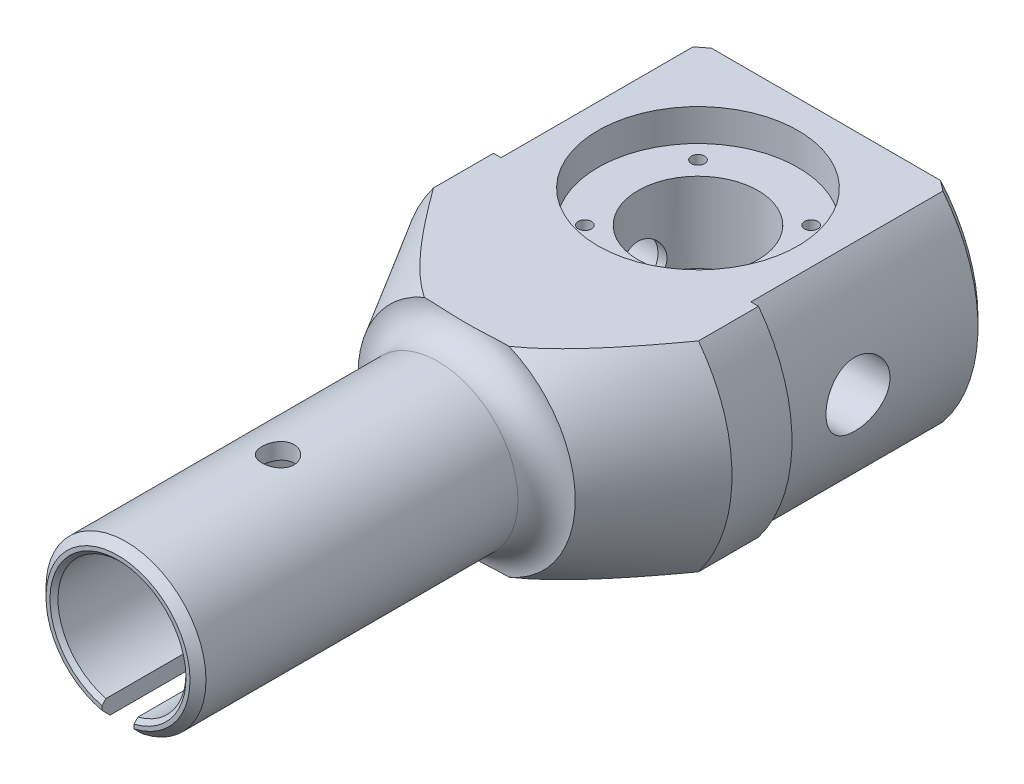
from build123d import *

# Parameters (mm, degrees)
SCHNITT_LINEAR_AUSTRAGEN1_REACH      = 179
SKIZZE3_R                            = 6
SCHNITT_LINEAR_AUSTRAGEN2_DEPTH      = 42.5
SCHNITT_LINEAR_AUSTRAGEN2_DEPTH_BACK = 42.5
SKIZZE4_R                            = 25
SCHNITT_LINEAR_AUSTRAGEN3_DEPTH      = 8
SKIZZE5_R                            = 15
SCHNITT_LINEAR_AUSTRAGEN4_DEPTH      = 20
KREISMUSTER1_COUNT                   = 4
SKIZZE9_R                            = 10
SCHNITT_LINEAR_AUSTRAGEN5_DEPTH      = 7.5
SCHNITT_LINEAR_AUSTRAGEN6_REACH      = 16.5
SKIZZE10_R                           = 7.5
SCHNITT_LINEAR_AUSTRAGEN7_REACH      = 27
SCHNITT_LINEAR_AUSTRAGEN8_REACH      = 27
SCHNITT_LINEAR_AUSTRAGEN8_END_RADIUS = 20
SKIZZE13_R                           = 4
SKIZZE14_R                           = 8
SCHNITT_LINEAR_AUSTRAGEN9_DEPTH      = 24
SKIZZE15_R                           = 8
SCHNITT_LINEAR_AUSTRAGEN10_DEPTH     = 24


with BuildPart() as part:
    # Skizze1 → Rotation1 (revolve)
    with BuildSketch(Plane(origin=(0, 0, 0), x_dir=(0, 0, -1), z_dir=(1, 0, 0)), mode=Mode.PRIVATE) as rotation1_sk:
        with BuildLine():
            Line((0, 0), (0, -38))
            Line((0, -38), (-2, -40))
            Line((-2, -40), (-50, -40))
            Line((-50, -40), (-50, -41.5))
            Line((-50, -41.5), (-65, -41.5))
            Line((-65, -41.5), (-89.84326674, -27.15673326))
            ThreePointArc((-89.84326674, -27.15673326), (-91.939425381, -22.096158641), (-97, -20))
            Line((-97, -20), (-175, -20))
            Line((-175, -20), (-177, -18))
            Line((-177, -18), (-177, -17))
            Line((-177, -17), (-176, -16))
            Line((-176, -16), (-86, -16))
            Line((-86, -16), (-76.386230096, 0))
            Line((-76.386230096, 0), (0, 0))
        make_face()
    revolve(rotation1_sk.sketch.rotate(Axis((0, 0, 212.688910887), (0, 0, -1)), 270), axis=Axis((0, 0, 212.688910887), (0, 0, -1)))  # turned: the seam where the file's is

    # Skizze2 → Schnitt-Linear austragen1 (cut, up to next)
    with BuildSketch(Plane(origin=(0, 0, 0), x_dir=(-1, 0, 0), z_dir=(0, 0, -1)), mode=Mode.PRIVATE) as schnitt_linear_austragen1_sk1:
        with BuildLine():
            Line((28.618176043, -25), (-28.618176043, -25))
            ThreePointArc((-28.618176043, -25), (0, -38), (28.618176043, -25))
        make_face()
    schnitt_linear_austragen1_tool1 = extrude(schnitt_linear_austragen1_sk1.sketch, amount=-SCHNITT_LINEAR_AUSTRAGEN1_REACH, mode=Mode.PRIVATE) & part.part
    add(schnitt_linear_austragen1_tool1.solids().sort_by_distance((0, -30.28468, 0))[0], mode=Mode.SUBTRACT)
    # Skizze2 → Schnitt-Linear austragen1 (cut, up to next)
    with BuildSketch(Plane(origin=(0, 0, 0), x_dir=(-1, 0, 0), z_dir=(0, 0, -1)), mode=Mode.PRIVATE) as schnitt_linear_austragen1_sk2:
        with BuildLine():
            ThreePointArc((28.618176043, 25), (0, 38), (-28.618176043, 25))
            Line((-28.618176043, 25), (28.618176043, 25))
        make_face()
    schnitt_linear_austragen1_tool2 = extrude(schnitt_linear_austragen1_sk2.sketch, amount=-SCHNITT_LINEAR_AUSTRAGEN1_REACH, mode=Mode.PRIVATE) & part.part
    add(schnitt_linear_austragen1_tool2.solids().sort_by_distance((0, 30.28468, 0))[0], mode=Mode.SUBTRACT)
    # Skizze2 → Schnitt-Linear austragen1 (cut, up to next)
    with BuildSketch(Plane(origin=(0, 0, 0), x_dir=(-1, 0, 0), z_dir=(0, 0, -1)), mode=Mode.PRIVATE) as schnitt_linear_austragen1_sk3:
        with BuildLine():
            ThreePointArc((33.749074061, 25), (0, 42), (-33.749074061, 25))
            Line((-33.749074061, 25), (-28.618176043, 25))
            ThreePointArc((-28.618176043, 25), (0, 38), (28.618176043, 25))
            Line((28.618176043, 25), (33.749074061, 25))
        make_face()
    schnitt_linear_austragen1_tool3 = extrude(schnitt_linear_austragen1_sk3.sketch, amount=-SCHNITT_LINEAR_AUSTRAGEN1_REACH, mode=Mode.PRIVATE) & part.part
    add(schnitt_linear_austragen1_tool3.solids().sort_by_distance((0, 38.69606, 0))[0], mode=Mode.SUBTRACT)
    # Skizze2 → Schnitt-Linear austragen1 (cut, up to next)
    with BuildSketch(Plane(origin=(0, 0, 0), x_dir=(-1, 0, 0), z_dir=(0, 0, -1)), mode=Mode.PRIVATE) as schnitt_linear_austragen1_sk4:
        with BuildLine():
            Line((-28.618176043, -25), (-33.749074061, -25))
            ThreePointArc((-33.749074061, -25), (0, -42), (33.749074061, -25))
            Line((33.749074061, -25), (28.618176043, -25))
            ThreePointArc((28.618176043, -25), (0, -38), (-28.618176043, -25))
        make_face()
    schnitt_linear_austragen1_tool4 = extrude(schnitt_linear_austragen1_sk4.sketch, amount=-SCHNITT_LINEAR_AUSTRAGEN1_REACH, mode=Mode.PRIVATE) & part.part
    add(schnitt_linear_austragen1_tool4.solids().sort_by_distance((31.183625, -25.69606, 0))[0], mode=Mode.SUBTRACT)

    # Skizze3 → Schnitt-Linear austragen2 (cut, two sides)
    with BuildSketch(Plane(origin=(0, 0, 0), x_dir=(0, 0, -1), z_dir=(1, 0, 0))) as schnitt_linear_austragen2_sk:
        with Locations((-32, 0)):
            Circle(SKIZZE3_R)
    extrude(amount=SCHNITT_LINEAR_AUSTRAGEN2_DEPTH, mode=Mode.SUBTRACT)
    extrude(schnitt_linear_austragen2_sk.sketch, amount=-SCHNITT_LINEAR_AUSTRAGEN2_DEPTH_BACK, mode=Mode.SUBTRACT)

    # Skizze4 → Schnitt-Linear austragen3 (cut)
    with BuildSketch(Plane(origin=(0, 25, 0), x_dir=(1, 0, 0), z_dir=(0, 1, 0))):
        with Locations(Location((0, -32, 0), (0, 0, 270))):  # turned: the seam where the file's is
            Circle(SKIZZE4_R)
    extrude(amount=-SCHNITT_LINEAR_AUSTRAGEN3_DEPTH, mode=Mode.SUBTRACT)

    # Skizze5 → Schnitt-Linear austragen4 (cut)
    with BuildSketch(Plane(origin=(0, 17, 0), x_dir=(1, 0, 0), z_dir=(0, 1, 0))):
        with Locations(Location((0, -32, 0), (0, 0, 270))):  # turned: the seam where the file's is
            Circle(SKIZZE5_R)
    extrude(amount=-SCHNITT_LINEAR_AUSTRAGEN4_DEPTH, mode=Mode.SUBTRACT)

    # Skizze7 → M4 Gewindebohrung1 (revolve, cut)
    with BuildSketch(Plane(origin=(-14.142135624, 17, 17.857864376), x_dir=(0, 0, 1), z_dir=(1, 0, 0))):
        Polygon((0, 0), (0, 12.491420021), (1.65, 11.5), (1.65, 0), align=None)
    m4_gewindebohrung1 = revolve(axis=Axis((-14.142135624, 23.35, 17.857864376), (0, -1, 0)), mode=Mode.SUBTRACT)

    # Kreismuster1: M4 Gewindebohrung1 ×4 about axis
    kreismuster1_axis = Axis((0, 0, 32), (0, 1, 0))
    for i in range(1, KREISMUSTER1_COUNT):
        add(m4_gewindebohrung1.rotate(kreismuster1_axis, i * 360 / KREISMUSTER1_COUNT), mode=Mode.SUBTRACT)

    # Skizze9 → Schnitt-Linear austragen5 (cut)
    with BuildSketch(Plane(origin=(0, -3, 0), x_dir=(1, 0, 0), z_dir=(0, 1, 0))):
        with Locations(Location((0, -32, 0), (0, 0, 270))):  # turned: the seam where the file's is
            Circle(SKIZZE9_R)
    extrude(amount=-SCHNITT_LINEAR_AUSTRAGEN5_DEPTH, mode=Mode.SUBTRACT)

    # Skizze10 → Schnitt-Linear austragen6 (cut, up to next)
    with BuildSketch(Plane(origin=(0, -10.5, 0), x_dir=(1, 0, 0), z_dir=(0, 1, 0)), mode=Mode.PRIVATE) as schnitt_linear_austragen6_sk1:
        with Locations(Location((0, -32, 0), (0, 0, 270))):  # turned: the seam where the file's is
            Circle(SKIZZE10_R)
    schnitt_linear_austragen6_tool1 = extrude(schnitt_linear_austragen6_sk1.sketch, amount=-SCHNITT_LINEAR_AUSTRAGEN6_REACH, mode=Mode.PRIVATE) & part.part
    add(schnitt_linear_austragen6_tool1.solids().sort_by_distance((0, -10.5, 32))[0], mode=Mode.SUBTRACT)

    # Skizze12 → Schnitt-Linear austragen7 (cut, up to next)
    with BuildSketch(Plane(origin=(0, 0, 0), x_dir=(1, 0, 0), z_dir=(0, 1, 0)), mode=Mode.PRIVATE) as schnitt_linear_austragen7_sk1:
        with BuildLine():
            Line((-4, -155), (-4, -177))
            Line((-4, -177), (4, -177))
            Line((4, -177), (4, -155))
            ThreePointArc((4, -155), (0, -151), (-4, -155))
        make_face()
    schnitt_linear_austragen7_tool1 = extrude(schnitt_linear_austragen7_sk1.sketch, amount=-SCHNITT_LINEAR_AUSTRAGEN7_REACH, mode=Mode.PRIVATE) & part.part
    add(schnitt_linear_austragen7_tool1.solids().sort_by_distance((0, 0, 164.413352))[0], mode=Mode.SUBTRACT)

    # Schnitt-Linear austragen8: up to this cylinder (the profile starts inside it)
    schnitt_linear_austragen8_end = Plane(origin=(0, 0, 137), z_dir=(0, 0, 1)) * Cylinder(SCHNITT_LINEAR_AUSTRAGEN8_END_RADIUS, 95, mode=Mode.PRIVATE)
    # Skizze13 → Schnitt-Linear austragen8 (cut, up to the surface)
    with BuildSketch(Plane(origin=(0, 0, 0), x_dir=(1, 0, 0), z_dir=(0, 1, 0)), mode=Mode.PRIVATE) as schnitt_linear_austragen8_sk1:
        with Locations(Location((0, -137, 0), (0, 0, 90))):  # turned: the seam where the file's is
            Circle(SKIZZE13_R)
    schnitt_linear_austragen8_tool1 = extrude(schnitt_linear_austragen8_sk1.sketch, amount=SCHNITT_LINEAR_AUSTRAGEN8_REACH, mode=Mode.PRIVATE) & schnitt_linear_austragen8_end
    add(schnitt_linear_austragen8_tool1.solids().sort_by_distance((0, 0, 137))[0], mode=Mode.SUBTRACT)

    # Skizze14 → Schnitt-Linear austragen9 (cut)
    with BuildSketch(Plane(origin=(40, 0, 2), x_dir=(0, 0, -1), z_dir=(1, 0, 0))):
        with Locations((-30, 0)):
            Circle(SKIZZE14_R)
    extrude(amount=-SCHNITT_LINEAR_AUSTRAGEN9_DEPTH, mode=Mode.SUBTRACT)

    # Skizze15 → Schnitt-Linear austragen10 (cut)
    with BuildSketch(Plane(origin=(-40, 0, 2), x_dir=(0, 0, 1), z_dir=(-1, 0, 0))):
        with Locations(Location((30, 0, 0), (0, 0, 180))):  # turned: the seam where the file's is
            Circle(SKIZZE15_R)
    extrude(amount=-SCHNITT_LINEAR_AUSTRAGEN10_DEPTH, mode=Mode.SUBTRACT)


solid = part.part
